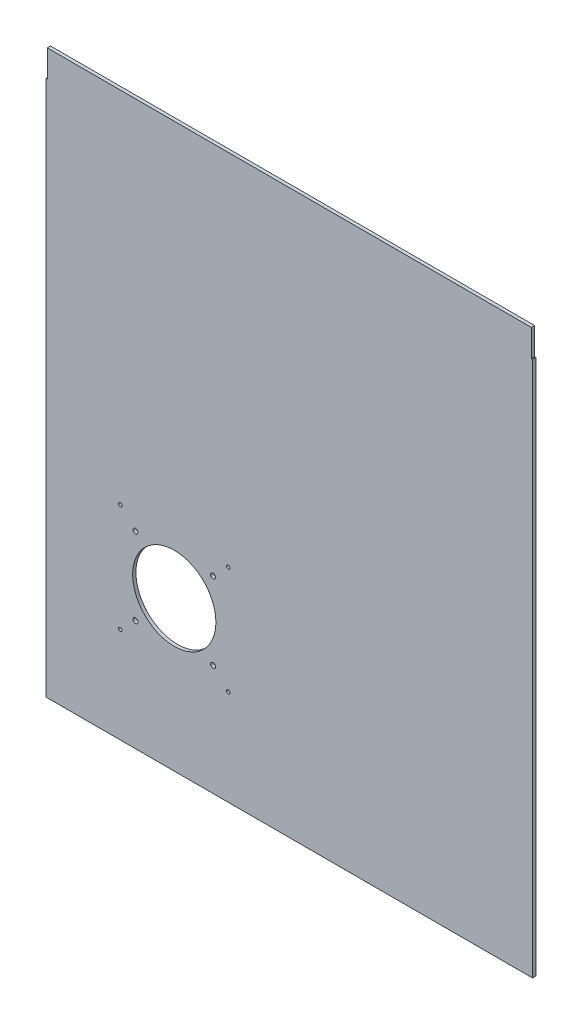
from build123d import *

# Parameters (mm, degrees)
SALIENTE_EXTRUIR1_DEPTH = 3
CROQUIS2_R              = 38.5
CROQUIS2_R_2            = 2.25
CROQUIS2_R_3            = 1.6
CORTAR_EXTRUIR1_DEPTH   = 3


with BuildPart() as part:
    # Croquis1 → Saliente-Extruir1 (new body)
    with BuildSketch(Plane.XY):
        Polygon((-261.838674033, 298.703267526), (-260.838674033, 298.703267526), (-260.838674033, 323.703267526), (187.161325967, 323.703267526), (187.161325967, 298.703267526), (188.161325967, 298.703267526), (188.161325967, -197.096732474), (-261.838674033, -197.096732474), align=None)
    extrude(amount=SALIENTE_EXTRUIR1_DEPTH)

    # Croquis2 → Cortar-Extruir1 (cut)
    with BuildSketch(Plane.XY.offset(3)):
        with Locations((-143.338674033, -58.596732474)):
            Circle(CROQUIS2_R)
        with Locations((-107.488674033, -22.746732474)):
            Circle(CROQUIS2_R_2)
        with Locations((-107.488674033, -94.446732474)):
            Circle(CROQUIS2_R_2)
        with Locations((-179.188674033, -94.446732474)):
            Circle(CROQUIS2_R_2)
        with Locations((-179.188674033, -22.746732474)):
            Circle(CROQUIS2_R_2)
        with Locations((-93.338674033, -8.596732474)):
            Circle(CROQUIS2_R_3)
        with Locations((-93.338674033, -108.596732474)):
            Circle(CROQUIS2_R_3)
        with Locations((-193.338674033, -108.596732474)):
            Circle(CROQUIS2_R_3)
        with Locations((-193.338674033, -8.596732474)):
            Circle(CROQUIS2_R_3)
    extrude(amount=-CORTAR_EXTRUIR1_DEPTH, mode=Mode.SUBTRACT)


solid = part.part
